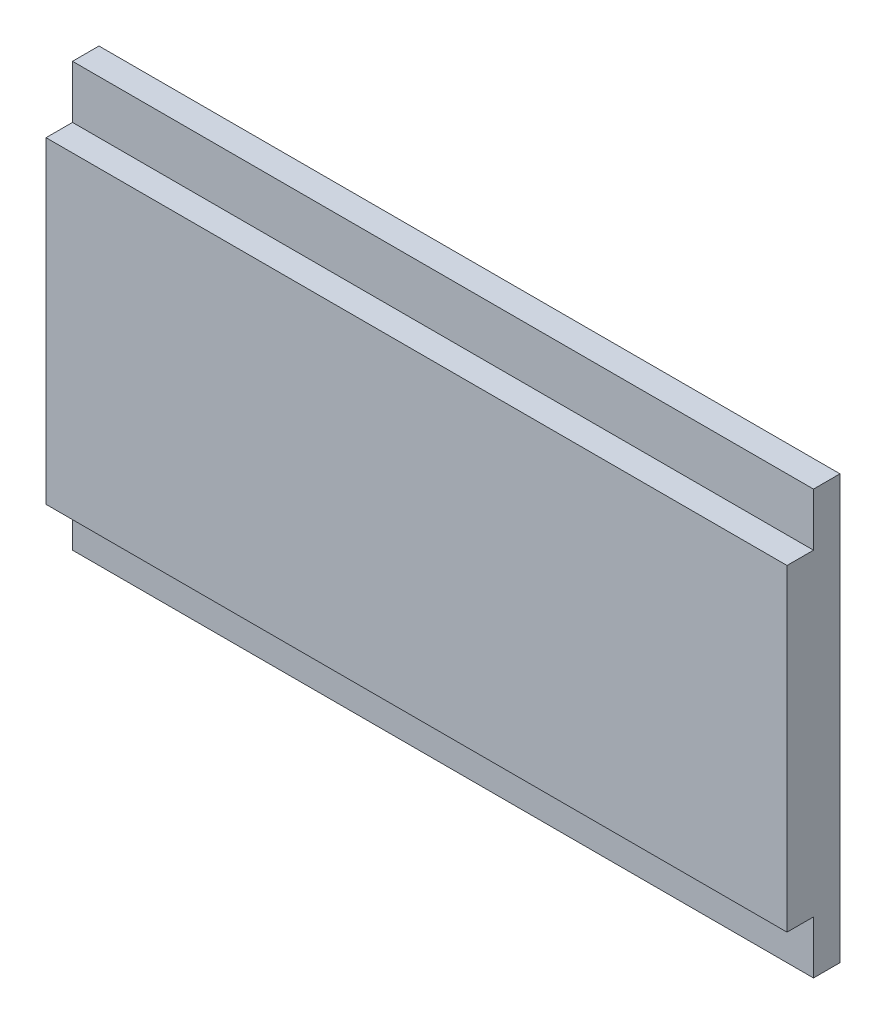
from build123d import *

# Parameters (mm, degrees)
SKETCH1_W           = 88.9
SKETCH1_H           = 38.1
BOSS_EXTRUDE1_DEPTH = 6.35
SKETCH2_W           = 88.9
SKETCH2_H           = 6.35
BOSS_EXTRUDE2_DEPTH = 3.175


with BuildPart() as part:
    # Sketch1 → Boss-Extrude1 (new body)
    with BuildSketch(Plane.XY):
        Rectangle(SKETCH1_W, SKETCH1_H)
    extrude(amount=BOSS_EXTRUDE1_DEPTH)

    # Sketch2 → Boss-Extrude2 (add)
    with BuildSketch(Plane(origin=(0, 0, 0), x_dir=(-1, 0, 0), z_dir=(0, 0, -1))):
        with Locations((0, 22.225)):
            Rectangle(SKETCH2_W, SKETCH2_H)
        with Locations((0, -22.225)):
            Rectangle(SKETCH2_W, SKETCH2_H)
    extrude(amount=-BOSS_EXTRUDE2_DEPTH)


solid = part.part
